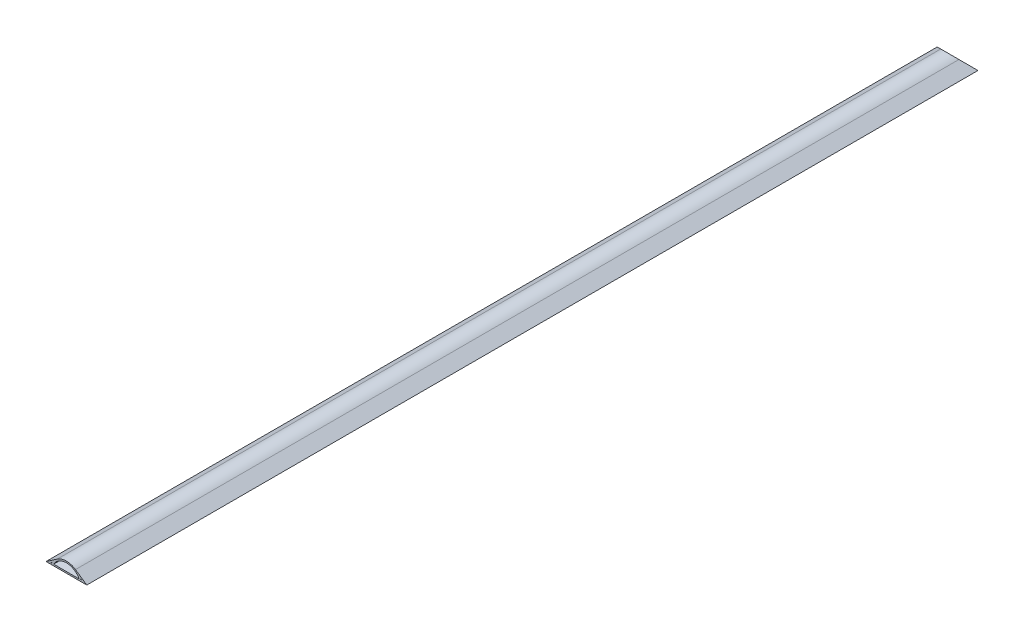
from build123d import *

# Parameters (mm, degrees)
BOSS_EXTRUDE1_DEPTH = 1498.6
CUT_EXTRUDE1_DEPTH  = 69.58


with BuildPart() as part:
    # Sketch2 → Boss-Extrude1 (new body)
    with BuildSketch(Plane.XY):
        with BuildLine():
            Line((0, 0), (68.58, 0))
            Line((68.58, 0), (49.587320143, 13.03542143))
            ThreePointArc((49.587320143, 13.03542143), (34.29, 17.78), (18.992679857, 13.03542143))
            Line((18.992679857, 13.03542143), (0, 0))
        make_face()
        with BuildLine():
            Line((10.997802271, 4.46752515), (8.189387654, 2.54))
            Line((8.189387654, 2.54), (9.965035751, 2.54))
            ThreePointArc((9.965035751, 2.54), (10.461920618, 3.514209799), (10.997802271, 4.46752515))
        make_face(mode=Mode.SUBTRACT)
        with BuildLine():
            Line((57.582197729, 4.46752515), (60.390612346, 2.54))
            Line((60.390612346, 2.54), (58.614964249, 2.54))
            ThreePointArc((58.614964249, 2.54), (58.118079382, 3.514209799), (57.582197729, 4.46752515))
        make_face(mode=Mode.SUBTRACT)
        with BuildLine():
            Line((12.82308193, 2.54), (55.75691807, 2.54))
            ThreePointArc((55.75691807, 2.54), (34.29, 15.24), (12.82308193, 2.54))
        make_face(mode=Mode.SUBTRACT)
    extrude(amount=BOSS_EXTRUDE1_DEPTH)

    # Sketch3 → Cut-Extrude1 (cut, through all)
    with BuildSketch(Plane(origin=(0, 0, 0), x_dir=(0, 0, -1), z_dir=(1, 0, 0))):
        Polygon((-17.78, 17.78), (0, 0), (0, 17.78), align=None)
    extrude(amount=CUT_EXTRUDE1_DEPTH, mode=Mode.SUBTRACT)


solid = part.part
